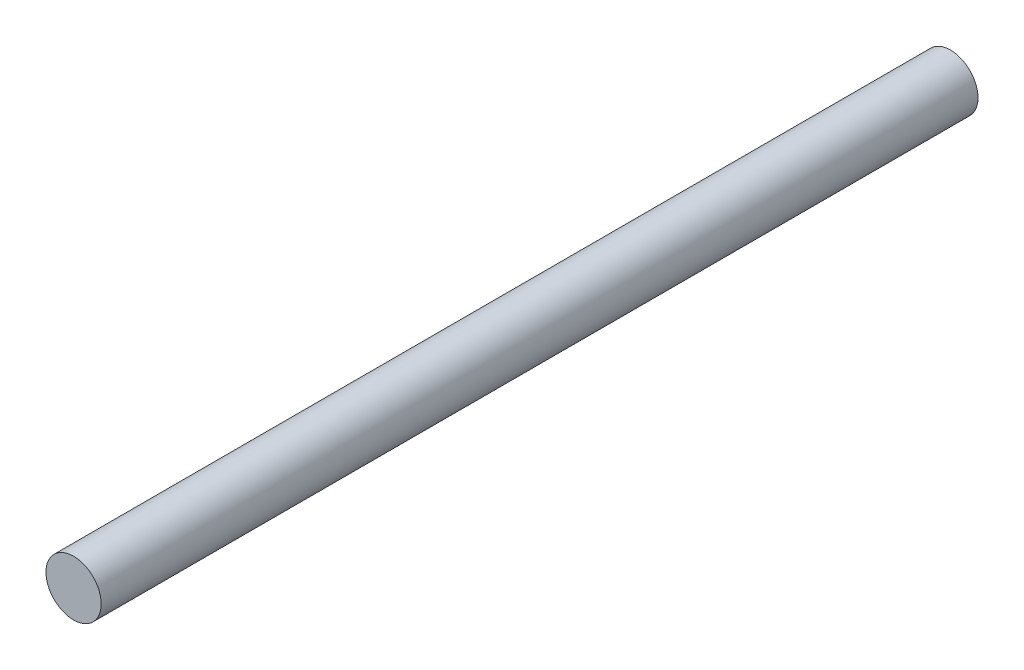
from build123d import *

# Parameters (mm, degrees)
SKETCH1_R           = 4
BOSS_EXTRUDE1_DEPTH = 127


with BuildPart() as part:
    # Sketch1 → Boss-Extrude1 (new body)
    with BuildSketch(Plane.XY):
        Circle(SKETCH1_R)
    extrude(amount=BOSS_EXTRUDE1_DEPTH)


solid = part.part
